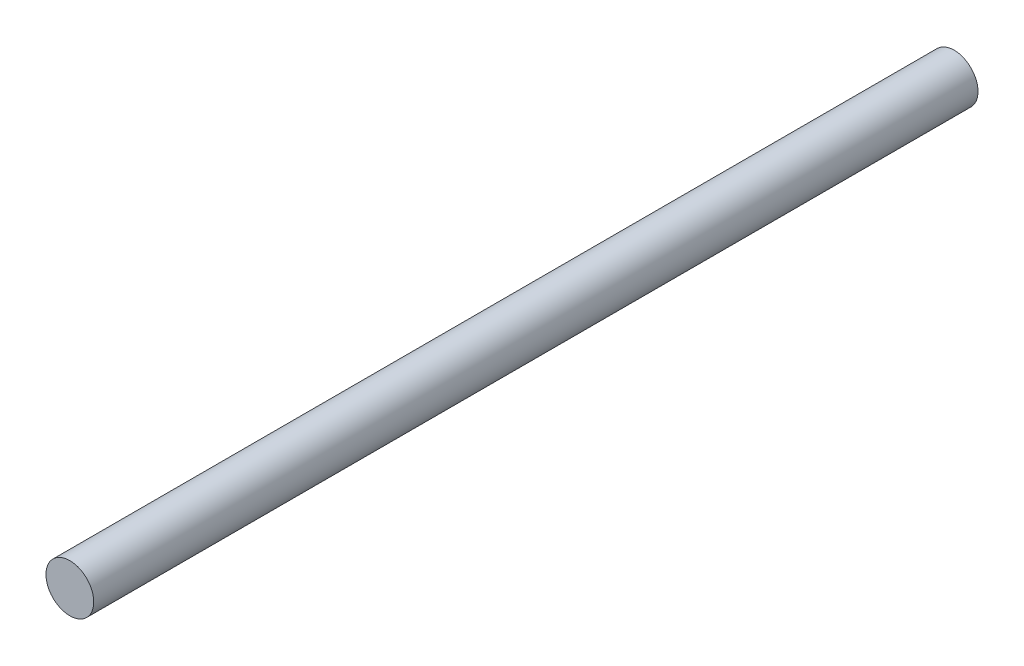
from build123d import *

# Parameters (mm, degrees)
SKETCH1_R           = 2
BOSS_EXTRUDE1_DEPTH = 74


with BuildPart() as part:
    # Sketch1 → Boss-Extrude1 (new body)
    with BuildSketch(Plane.XY):
        Circle(SKETCH1_R)
    extrude(amount=BOSS_EXTRUDE1_DEPTH)


solid = part.part
